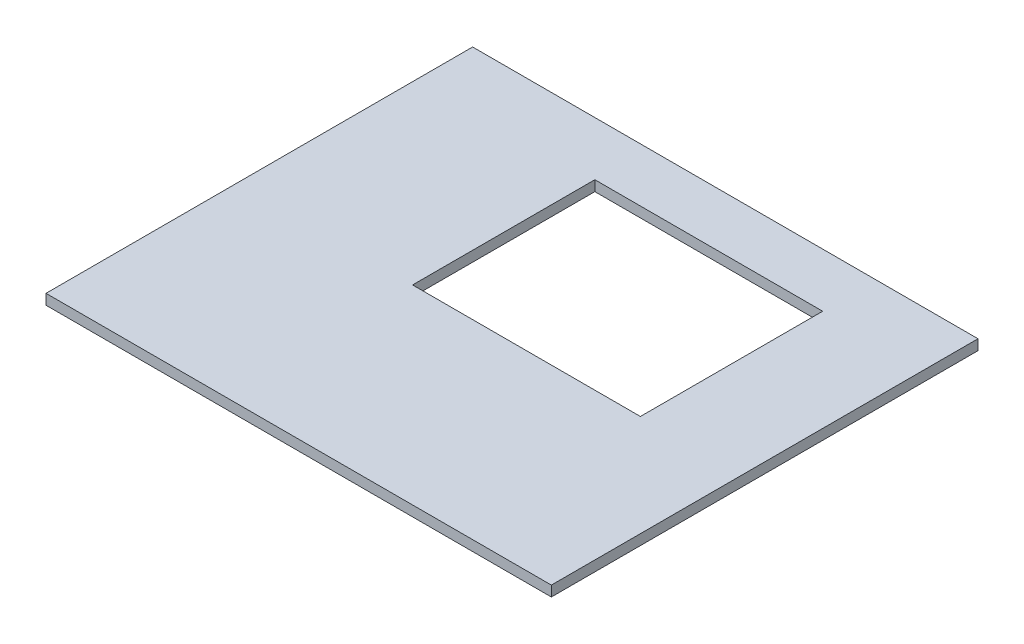
from build123d import *

# Parameters (mm, degrees)
SKETCH1_W           = 119
SKETCH1_H           = 103
BOSS_EXTRUDE1_DEPTH = 2.5
SKETCH3_W           = 55
SKETCH3_H           = 44
CUT_EXTRUDE2_DEPTH  = 10
SKETCH4_W           = 103
SKETCH4_H           = 2.5
BOSS_EXTRUDE2_DEPTH = 1.5
SKETCH5_W           = 103
SKETCH5_H           = 2.5
BOSS_EXTRUDE3_DEPTH = 1.5


with BuildPart() as part:
    # Sketch1 → Boss-Extrude1 (new body)
    with BuildSketch(Plane(origin=(0, 0, 0), x_dir=(1, 0, 0), z_dir=(0, 1, 0))):
        Rectangle(SKETCH1_W, SKETCH1_H)
    extrude(amount=BOSS_EXTRUDE1_DEPTH)

    # Sketch3 → Cut-Extrude2 (cut)
    with BuildSketch(Plane(origin=(0, 2.5, 0), x_dir=(1, 0, 0), z_dir=(0, 1, 0))):
        with Locations((9, 16.5)):
            Rectangle(SKETCH3_W, SKETCH3_H)
    extrude(amount=-CUT_EXTRUDE2_DEPTH, mode=Mode.SUBTRACT)

    # Sketch4 → Boss-Extrude2 (add)
    with BuildSketch(Plane.ZY.offset(59.5)):
        with Locations((0, 1.25)):
            Rectangle(SKETCH4_W, SKETCH4_H)
    extrude(amount=BOSS_EXTRUDE2_DEPTH)

    # Sketch5 → Boss-Extrude3 (add)
    with BuildSketch(Plane(origin=(59.5, 0, 0), x_dir=(0, 0, -1), z_dir=(1, 0, 0))):
        with Locations((0, 1.25)):
            Rectangle(SKETCH5_W, SKETCH5_H)
    extrude(amount=BOSS_EXTRUDE3_DEPTH)


solid = part.part
